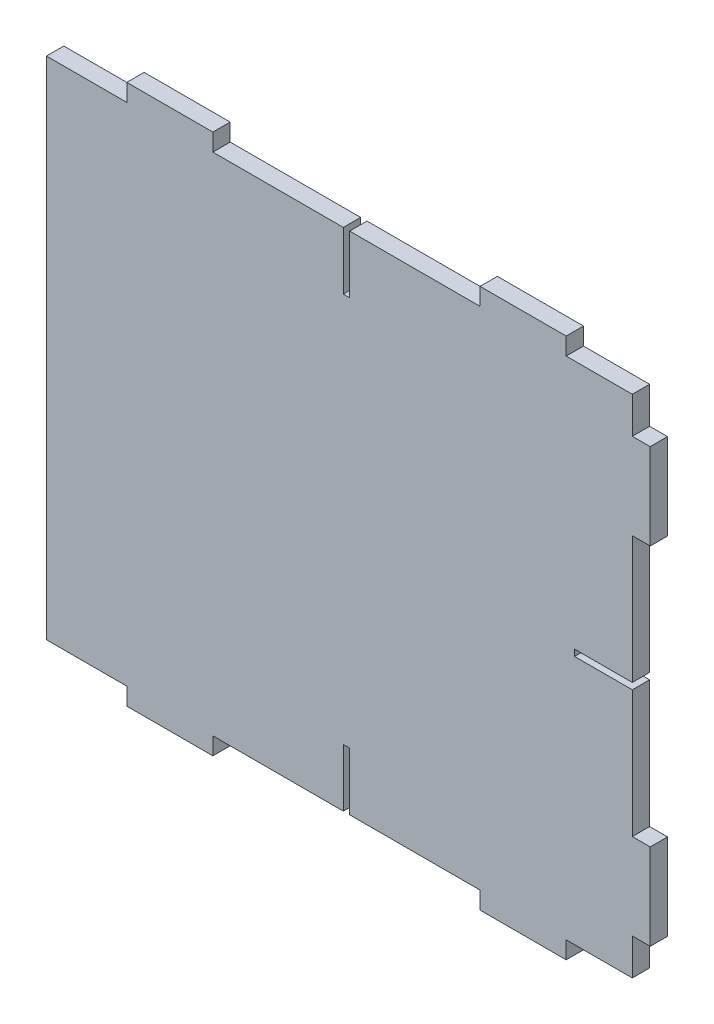
from build123d import *

# Parameters (mm, degrees)
RESSALTO_EXTRUS_O1_DEPTH = 6
ESBO_O2_W                = 2.2
ESBO_O2_H                = 20
ESBO_O2_W_2              = 20
ESBO_O2_H_2              = 2.2
CORTE_EXTRUS_O1_DEPTH    = 6


with BuildPart() as part:
    # Esboço1 → Ressalto-extrusão1 (new body)
    with BuildSketch(Plane.XY):
        Polygon((150.105265805, 0), (179.905265805, 0), (179.905265805, 6), (202.8, 6), (202.8, 18.6), (209, 18.6), (209, 48.4), (202.8, 48.4), (202.8, 138.6), (209, 138.6), (209, 168.4), (202.8, 168.4), (202.8, 181), (179.905265805, 181), (179.905265805, 187), (150.105265805, 187), (150.105265805, 181), (57.605265805, 181), (57.605265805, 187), (27.805265805, 187), (27.805265805, 181), (0, 181), (0, 6), (27.805265805, 6), (27.805265805, 0), (57.605265805, 0), (57.605265805, 6), (150.105265805, 6), align=None)
    extrude(amount=RESSALTO_EXTRUS_O1_DEPTH)

    # Esboço2 → Corte-extrusão1 (cut)
    with BuildSketch(Plane.XY.offset(6)):
        with Locations((103.857898708, 171)):
            Rectangle(ESBO_O2_W, ESBO_O2_H)
        with Locations((192.8, 93.5)):
            Rectangle(ESBO_O2_W_2, ESBO_O2_H_2)
        with Locations((103.857898708, 16)):
            Rectangle(ESBO_O2_W, ESBO_O2_H)
    extrude(amount=-CORTE_EXTRUS_O1_DEPTH, mode=Mode.SUBTRACT)


solid = part.part
